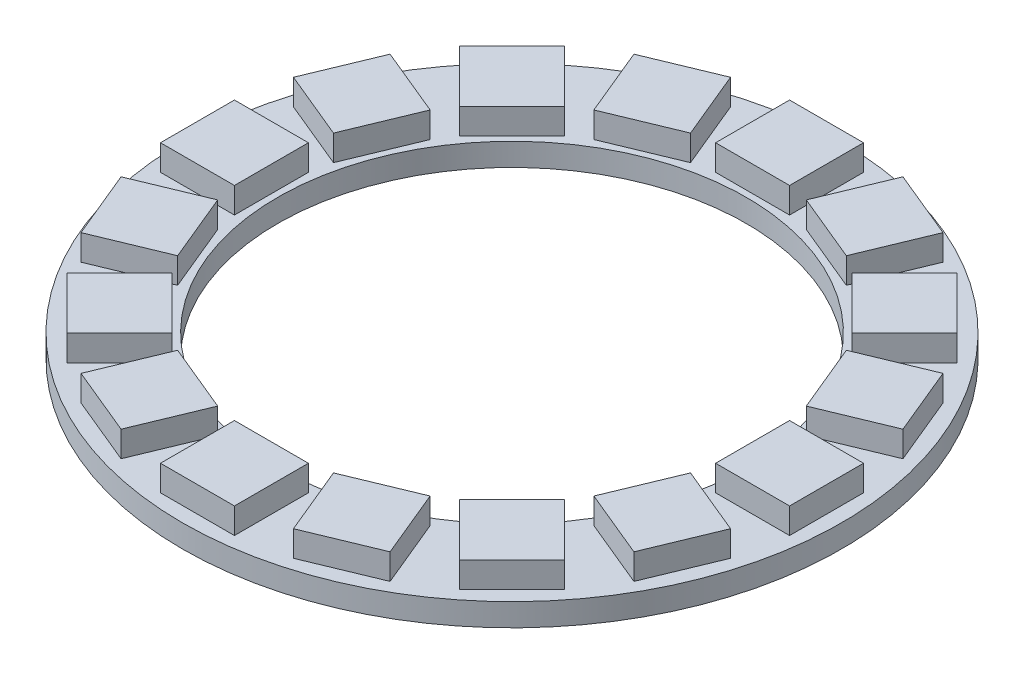
from build123d import *

# Parameters (mm, degrees)
SKETCH1_R           = 22.5
SKETCH1_R_2         = 16
BOSS_EXTRUDE1_DEPTH = 1.55
SKETCH2_W           = 5.05
SKETCH2_H           = 5.05
BOSS_EXTRUDE2_DEPTH = 1.75
CIRPATTERN1_COUNT   = 16


with BuildPart() as part:
    # Sketch1 → Boss-Extrude1 (new body)
    with BuildSketch(Plane(origin=(0, 0, 0), x_dir=(1, 0, 0), z_dir=(0, 1, 0))):
        Circle(SKETCH1_R)
        Circle(SKETCH1_R_2, mode=Mode.SUBTRACT)
    extrude(amount=BOSS_EXTRUDE1_DEPTH)

    # Sketch2 → Boss-Extrude2 (add)
    with BuildSketch(Plane(origin=(0, 1.55, 0), x_dir=(1, 0, 0), z_dir=(0, 1, 0))):
        with Locations((0, 18.95)):
            Rectangle(SKETCH2_W, SKETCH2_H)
    boss_extrude2 = extrude(amount=BOSS_EXTRUDE2_DEPTH)

    # CirPattern1: Boss-Extrude2 ×16 about axis
    cirpattern1_axis = Axis((0, 0, 0), (0, 1, 0))
    for i in range(1, CIRPATTERN1_COUNT):
        add(boss_extrude2.rotate(cirpattern1_axis, i * 360 / CIRPATTERN1_COUNT))


solid = part.part
